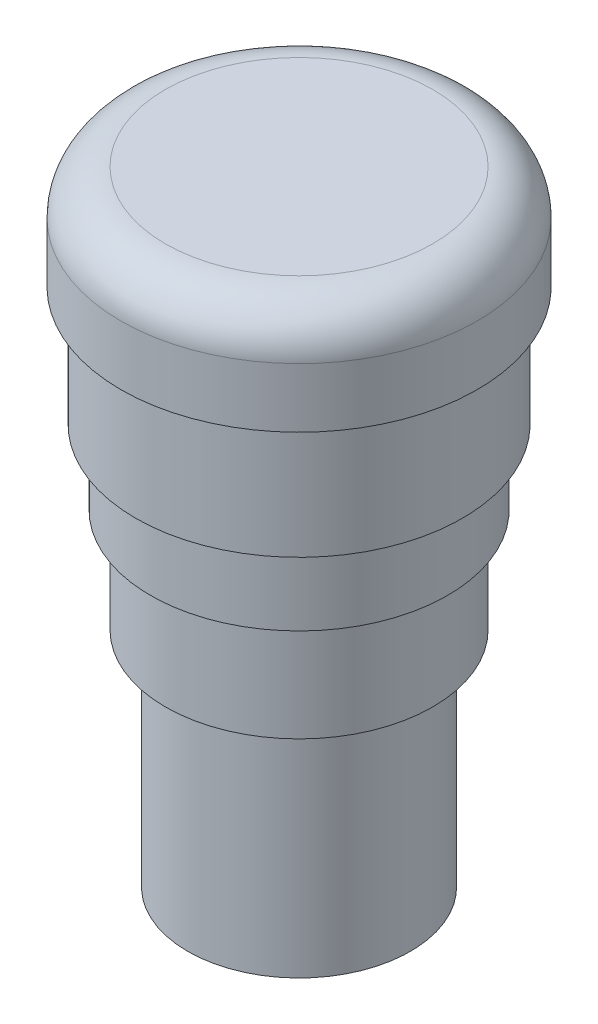
from build123d import *

# Parameters (mm, degrees)
ESQUISSE1_R      = 12
EXTRUSION1_DEPTH = 7
ESQUISSE2_R      = 11
EXTRUSION2_DEPTH = 8
CONG_1_R         = 3
ESQUISSE3_R      = 10
EXTRUSION3_DEPTH = 5
ESQUISSE4_R      = 9
EXTRUSION4_DEPTH = 7
ESQUISSE5_R      = 7.5
EXTRUSION5_DEPTH = 15


with BuildPart() as part:
    # Esquisse1 → Extrusion1 (new body)
    with BuildSketch(Plane(origin=(0, 0, 0), x_dir=(1, 0, 0), z_dir=(0, 1, 0))):
        Circle(ESQUISSE1_R)
    extrude(amount=EXTRUSION1_DEPTH)

    # Esquisse2 → Extrusion2 (add)
    with BuildSketch(Plane.XZ):
        Circle(ESQUISSE2_R)
    extrude(amount=EXTRUSION2_DEPTH)

    # Congé1
    cong_1_edges = [part.edges().sort_by_distance(p)[0] for p in [
        (-12, 7, 0),
    ]]
    fillet(cong_1_edges, radius=CONG_1_R)

    # Esquisse3 → Extrusion3 (add)
    with BuildSketch(Plane.XZ.offset(8)):
        Circle(ESQUISSE3_R)
    extrude(amount=EXTRUSION3_DEPTH)

    # Esquisse4 → Extrusion4 (add)
    with BuildSketch(Plane.XZ.offset(13)):
        Circle(ESQUISSE4_R)
    extrude(amount=EXTRUSION4_DEPTH)

    # Esquisse5 → Extrusion5 (add)
    with BuildSketch(Plane.XZ.offset(20)):
        Circle(ESQUISSE5_R)
    extrude(amount=EXTRUSION5_DEPTH)


solid = part.part
